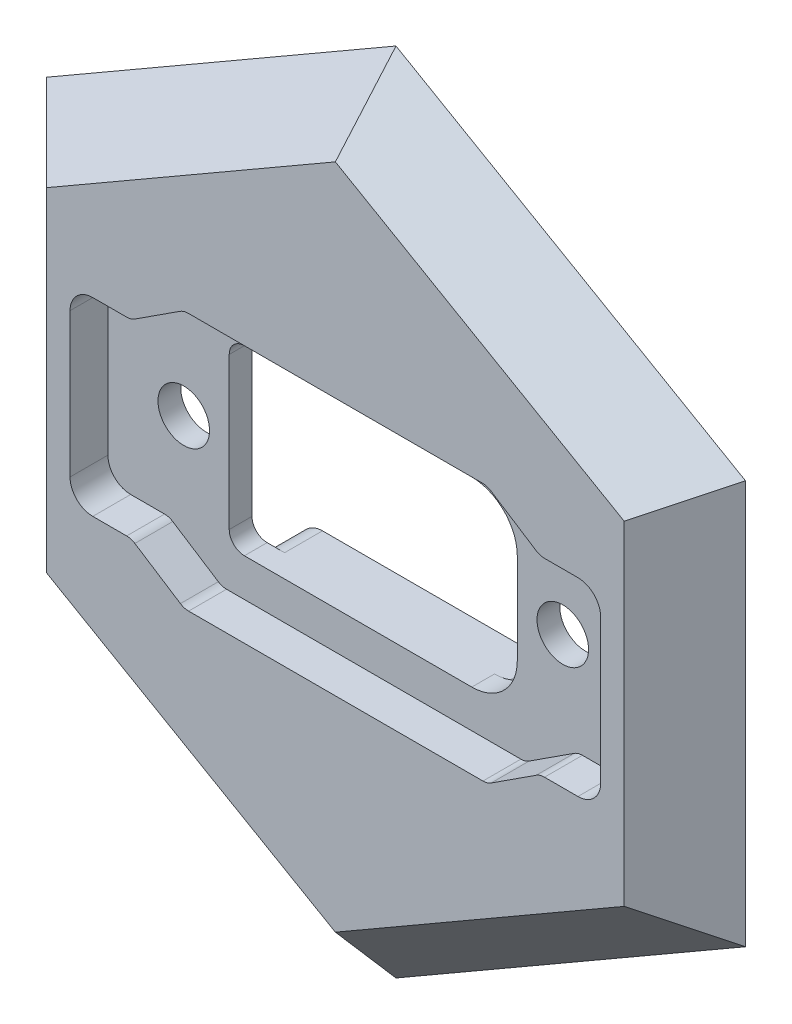
from build123d import *

# Parameters (mm, degrees)
SKETCH1_R           = 28
BOSS_EXTRUDE1_DEPTH = 4
BOSS_EXTRUDE2_DEPTH = 2.5
CUT_EXTRUDE1_DEPTH  = 2.5
CUT_EXTRUDE2_DEPTH  = 7.5
SKETCH5_R           = 1.7
CUT_EXTRUDE3_DEPTH  = 5
SKETCH7_OUTSIDE_W   = 88.892
SKETCH7_OUTSIDE_H   = 88.892
CUT_EXTRUDE4_DEPTH  = 7.5
CUT_EXTRUDE4_TAPER  = 45


with BuildPart() as part:
    # Sketch1 → Boss-Extrude1 (new body)
    with BuildSketch(Plane.XY):
        Circle(SKETCH1_R)
    extrude(amount=BOSS_EXTRUDE1_DEPTH)

    # Sketch2 → Boss-Extrude2 (add)
    with BuildSketch(Plane(origin=(0, 0, 0), x_dir=(-1, 0, 0), z_dir=(0, 0, -1))):
        with BuildLine():
            Line((-7.348469228, -6), (7.348469228, -6))
            ThreePointArc((7.348469228, -6), (8.737199378, -6.93305329), (8.398250547, -8.571428571))
            ThreePointArc((8.398250547, -8.571428571), (0, -12), (-8.398250547, -8.571428571))
            ThreePointArc((-8.398250547, -8.571428571), (-8.737199378, -6.93305329), (-7.348469228, -6))
        make_face()
        with BuildLine():
            Line((7.348469228, 6), (-7.348469228, 6))
            ThreePointArc((-7.348469228, 6), (-8.737199378, 6.93305329), (-8.398250547, 8.571428571))
            ThreePointArc((-8.398250547, 8.571428571), (0, 12), (8.398250547, 8.571428571))
            ThreePointArc((8.398250547, 8.571428571), (8.737199378, 6.93305329), (7.348469228, 6))
        make_face()
    extrude(amount=BOSS_EXTRUDE2_DEPTH)

    # Sketch3 → Cut-Extrude1 (cut)
    with BuildSketch(Plane.XY.offset(4)):
        with BuildLine():
            Line((-17.5, 4.75), (-17.5, -4.75))
            ThreePointArc((-17.5, -4.75), (-17.060660172, -5.810660172), (-16, -6.25))
            Line((-16, -6.25), (-13.765564437, -6.25))
            ThreePointArc((-13.765564437, -6.25), (-13.483765285, -6.290526583), (-13.224806846, -6.408821525))
            Line((-13.224806846, -6.408821525), (-10.218918256, -8.341178475))
            ThreePointArc((-10.218918256, -8.341178475), (-9.959959817, -8.459473417), (-9.678160664, -8.5))
            Line((-9.678160664, -8.5), (9.734435563, -8.5))
            ThreePointArc((9.734435563, -8.5), (10.018134319, -8.458913456), (10.278520672, -8.339030031))
            Line((10.278520672, -8.339030031), (13.251769281, -6.410969969))
            ThreePointArc((13.251769281, -6.410969969), (13.512155635, -6.291086544), (13.795854391, -6.25))
            Line((13.795854391, -6.25), (16, -6.25))
            ThreePointArc((16, -6.25), (17.060660172, -5.810660172), (17.5, -4.75))
            Line((17.5, -4.75), (17.5, 4.75))
            ThreePointArc((17.5, 4.75), (17.060660172, 5.810660172), (16, 6.25))
            Line((16, 6.25), (13.793701886, 6.25))
            ThreePointArc((13.793701886, 6.25), (13.511902734, 6.290526583), (13.252944295, 6.408821525))
            Line((13.252944295, 6.408821525), (10.247055705, 8.341178475))
            ThreePointArc((10.247055705, 8.341178475), (9.988097266, 8.459473417), (9.706298114, 8.5))
            Line((9.706298114, 8.5), (-9.704145609, 8.5))
            ThreePointArc((-9.704145609, 8.5), (-9.987844365, 8.458913456), (-10.248230719, 8.339030031))
            Line((-10.248230719, 8.339030031), (-13.221479328, 6.410969969))
            ThreePointArc((-13.221479328, 6.410969969), (-13.481865681, 6.291086544), (-13.765564437, 6.25))
            Line((-13.765564437, 6.25), (-16, 6.25))
            ThreePointArc((-16, 6.25), (-17.060660172, 5.810660172), (-17.5, 4.75))
        make_face()
    extrude(amount=-CUT_EXTRUDE1_DEPTH, mode=Mode.SUBTRACT)

    # Sketch4 → Cut-Extrude2 (cut, through all)
    with BuildSketch(Plane(origin=(0, 0, -2.5), x_dir=(-1, 0, 0), z_dir=(0, 0, -1))):
        with BuildLine():
            Line((-6.5, -6), (8.5, -6))
            ThreePointArc((8.5, -6), (9.207106781, -5.707106781), (9.5, -5))
            Line((9.5, -5), (9.5, 5))
            ThreePointArc((9.5, 5), (9.207106781, 5.707106781), (8.5, 6))
            Line((8.5, 6), (-6.5, 6))
            ThreePointArc((-6.5, 6), (-8.621320344, 5.121320344), (-9.5, 3))
            Line((-9.5, 3), (-9.5, -3))
            ThreePointArc((-9.5, -3), (-8.621320344, -5.121320344), (-6.5, -6))
        make_face()
    extrude(amount=-CUT_EXTRUDE2_DEPTH, mode=Mode.SUBTRACT)

    # Sketch5 → Cut-Extrude3 (cut, through all)
    with BuildSketch(Plane.XY.offset(1.5)):
        with Locations((-12.5, 0)):
            Circle(SKETCH5_R)
        with Locations((12.5, 0)):
            Circle(SKETCH5_R)
    extrude(amount=-CUT_EXTRUDE3_DEPTH, mode=Mode.SUBTRACT)

    # Sketch7 outside → Cut-Extrude4 (cut, through all)
    with BuildSketch(Plane.XY.offset(4)):
        Rectangle(SKETCH7_OUTSIDE_W, SKETCH7_OUTSIDE_H)
        Polygon((0, 22), (-19.052558883, 11), (-19.052558883, -11), (0, -22), (19.052558883, -11), (19.052558883, 11), align=None, mode=Mode.SUBTRACT)
    extrude(amount=-CUT_EXTRUDE4_DEPTH, taper=CUT_EXTRUDE4_TAPER, mode=Mode.SUBTRACT)


solid = part.part
